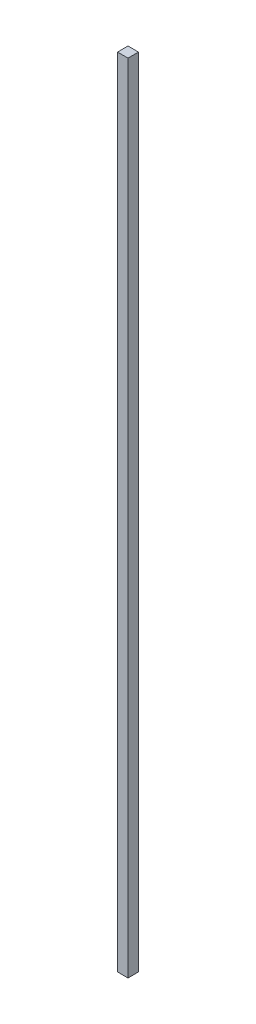
from build123d import *

# Parameters (mm, degrees)
SKETCH1_W           = 3.175
SKETCH1_H           = 3.175
BOSS_EXTRUDE1_DEPTH = 241.3


with BuildPart() as part:
    # Sketch1 → Boss-Extrude1 (new body)
    with BuildSketch(Plane(origin=(0, 0, 0), x_dir=(1, 0, 0), z_dir=(0, 1, 0))):
        with Locations((1.5875, 1.5875)):
            Rectangle(SKETCH1_W, SKETCH1_H)
    extrude(amount=BOSS_EXTRUDE1_DEPTH)


solid = part.part
